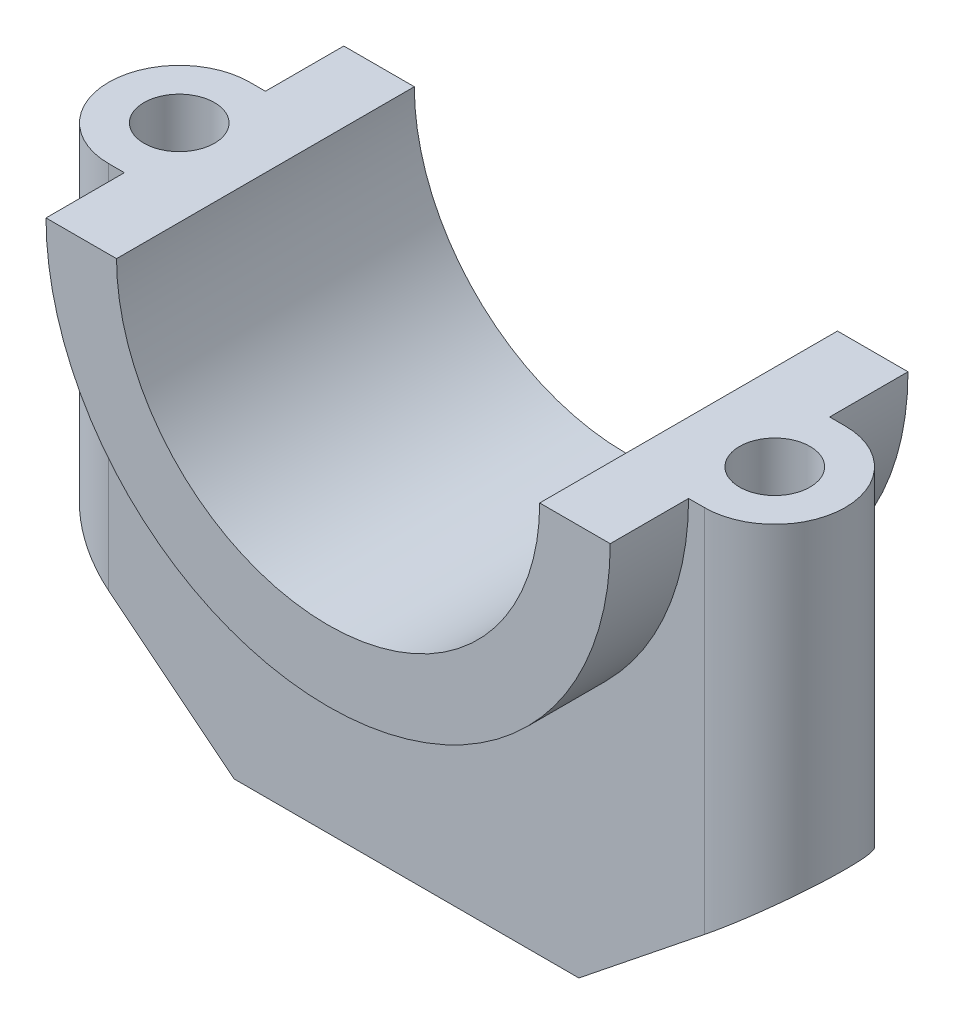
from build123d import *

# Parameters (mm, degrees)
BOSS_EXTRUDE2_DEPTH  = 38
BOSS_EXTRUDE3_DEPTH  = 9
SKETCH5_R            = 9
BOSS_EXTRUDE4_DEPTH  = 40
CUT_EXTRUDE1_DEPTH   = 61
MIRROR2_COPY_1_DEPTH = 61
CUT_EXTRUDE3_DEPTH   = 40
SKETCH7_R            = 4.5
CUT_EXTRUDE4_DEPTH   = 61


with BuildPart() as part:
    # Sketch1 → Boss-Extrude2 (new body)
    with BuildSketch(Plane.XY):
        with BuildLine():
            Line((27, 0), (36, 0))
            ThreePointArc((36, 0), (0, -36), (-36, 0))
            Line((-36, 0), (-27, 0))
            Line((-27, 0), (27, 0))
        make_face()
    extrude(amount=BOSS_EXTRUDE2_DEPTH)

    # Sketch4 → Boss-Extrude3 (add, symmetric)
    with BuildSketch(Plane.XY.offset(19)):
        with BuildLine():
            Line((-36, 0), (-47, 0))
            Line((-47, 0), (-47, -40))
            Line((-47, -40), (-22, -60))
            Line((-22, -60), (22, -60))
            Line((22, -60), (47, -40))
            Line((47, -40), (47, 0))
            Line((47, 0), (36, 0))
            ThreePointArc((36, 0), (0, -36), (-36, 0))
        make_face()
    extrude(amount=BOSS_EXTRUDE3_DEPTH, both=True)

    # Sketch5 → Boss-Extrude4 (add)
    with BuildSketch(Plane(origin=(0, 0, 0), x_dir=(1, 0, 0), z_dir=(0, 1, 0))):
        with Locations((-38, -19)):
            Circle(SKETCH5_R)
        with Locations((38, -19)):
            Circle(SKETCH5_R)
    extrude(amount=-BOSS_EXTRUDE4_DEPTH)

    # Sketch6 → Cut-Extrude1 (cut, through all)
    with BuildSketch(Plane(origin=(0, 0, 0), x_dir=(1, 0, 0), z_dir=(0, 1, 0))):
        with BuildLine():
            Line((-47, -19), (-47, -10))
            Line((-47, -10), (-38, -10))
            ThreePointArc((-38, -10), (-44.363961031, -12.636038969), (-47, -19))
        make_face()
    cut_extrude1 = extrude(amount=-CUT_EXTRUDE1_DEPTH, mode=Mode.SUBTRACT)

    # Mirror1: Cut-Extrude1 across plane
    add(cut_extrude1.mirror(Plane.XY.offset(19)), mode=Mode.SUBTRACT)

    # Mirror2: Cut-Extrude1 across plane
    add(cut_extrude1.mirror(Plane(origin=(0, 0, 0), x_dir=(0, 0, 1), z_dir=(1, 0, 0))), mode=Mode.SUBTRACT)

    # Mirror2 copy 1 sketch → Mirror2 copy 1 (cut, through all)
    with BuildSketch(Plane(origin=(0, 0, 38), x_dir=(-1, 0, 0), z_dir=(0, 1, 0))):
        with BuildLine():
            Line((-47, -19), (-47, -10))
            Line((-47, -10), (-38, -10))
            ThreePointArc((-38, -10), (-44.363961031, -12.636038969), (-47, -19))
        make_face()
    extrude(amount=-MIRROR2_COPY_1_DEPTH, mode=Mode.SUBTRACT)

    # Sketch3 → Cut-Extrude3 (cut)
    with BuildSketch(Plane.XY.offset(38)):
        with BuildLine():
            Line((-27, 0), (27, 0))
            ThreePointArc((27, 0), (0, -27), (-27, 0))
        make_face()
    extrude(amount=-CUT_EXTRUDE3_DEPTH, mode=Mode.SUBTRACT)

    # Sketch7 → Cut-Extrude4 (cut, through all)
    with BuildSketch(Plane(origin=(0, 0, 0), x_dir=(1, 0, 0), z_dir=(0, 1, 0))):
        with Locations((-38, -19)):
            Circle(SKETCH7_R)
        with Locations((38, -19)):
            Circle(SKETCH7_R)
    extrude(amount=-CUT_EXTRUDE4_DEPTH, mode=Mode.SUBTRACT)


solid = part.part
